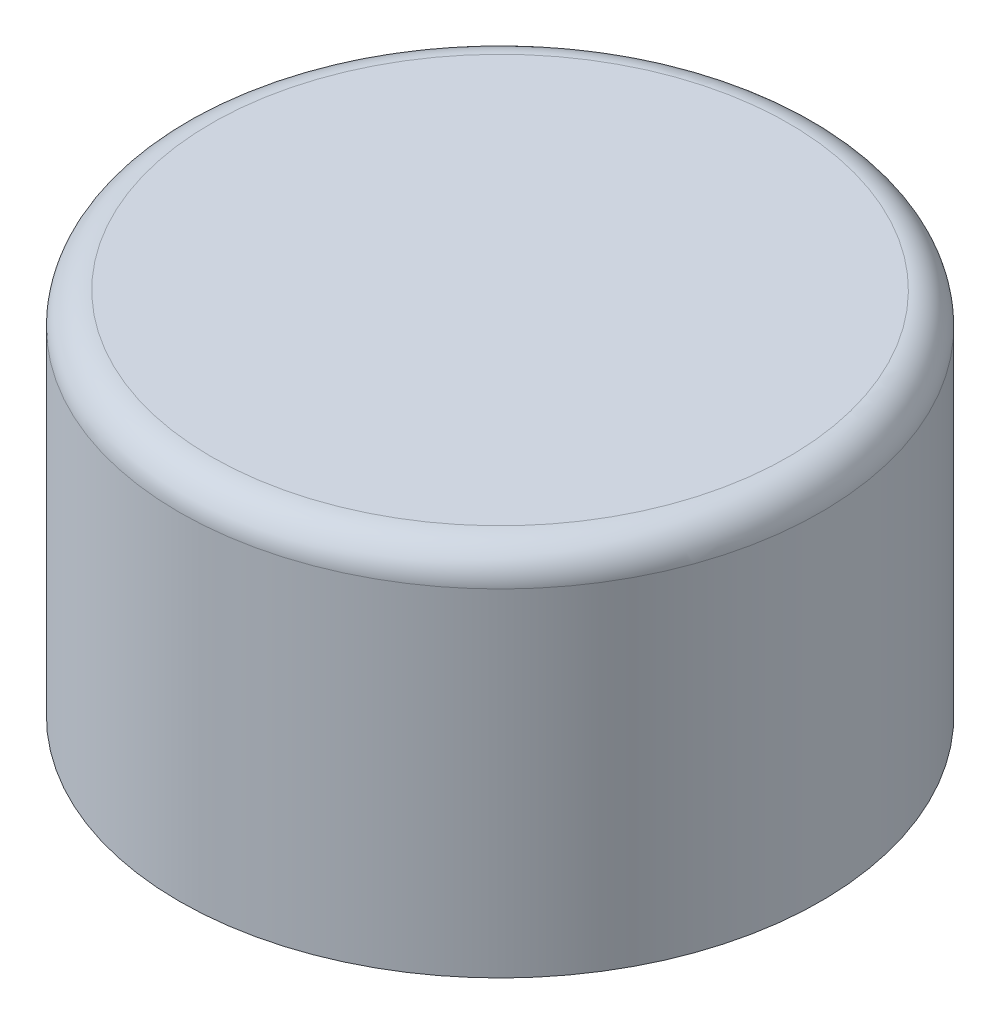
from build123d import *

# Parameters (mm, degrees)
SKETCH2_R           = 50.8
SKETCH2_R_2         = 44.45
BOSS_EXTRUDE2_DEPTH = 50.8
SKETCH6_R           = 50.8
BOSS_EXTRUDE3_DEPTH = 7.62
FILLET1_R           = 5.08


with BuildPart() as part:
    # Sketch2 → Boss-Extrude2 (new body)
    with BuildSketch(Plane(origin=(0, 0, 0), x_dir=(1, 0, 0), z_dir=(0, 1, 0))):
        Circle(SKETCH2_R)
        Circle(SKETCH2_R_2, mode=Mode.SUBTRACT)
    extrude(amount=BOSS_EXTRUDE2_DEPTH)

    # Sketch6 → Boss-Extrude3 (add)
    with BuildSketch(Plane(origin=(0, 50.8, 0), x_dir=(1, 0, 0), z_dir=(0, 1, 0))):
        Circle(SKETCH6_R)
    extrude(amount=BOSS_EXTRUDE3_DEPTH)

    # Fillet1
    fillet1_edges = [part.edges().sort_by_distance(p)[0] for p in [
        (-50.8, 58.42, 0),
    ]]
    fillet(fillet1_edges, radius=FILLET1_R)


solid = part.part
